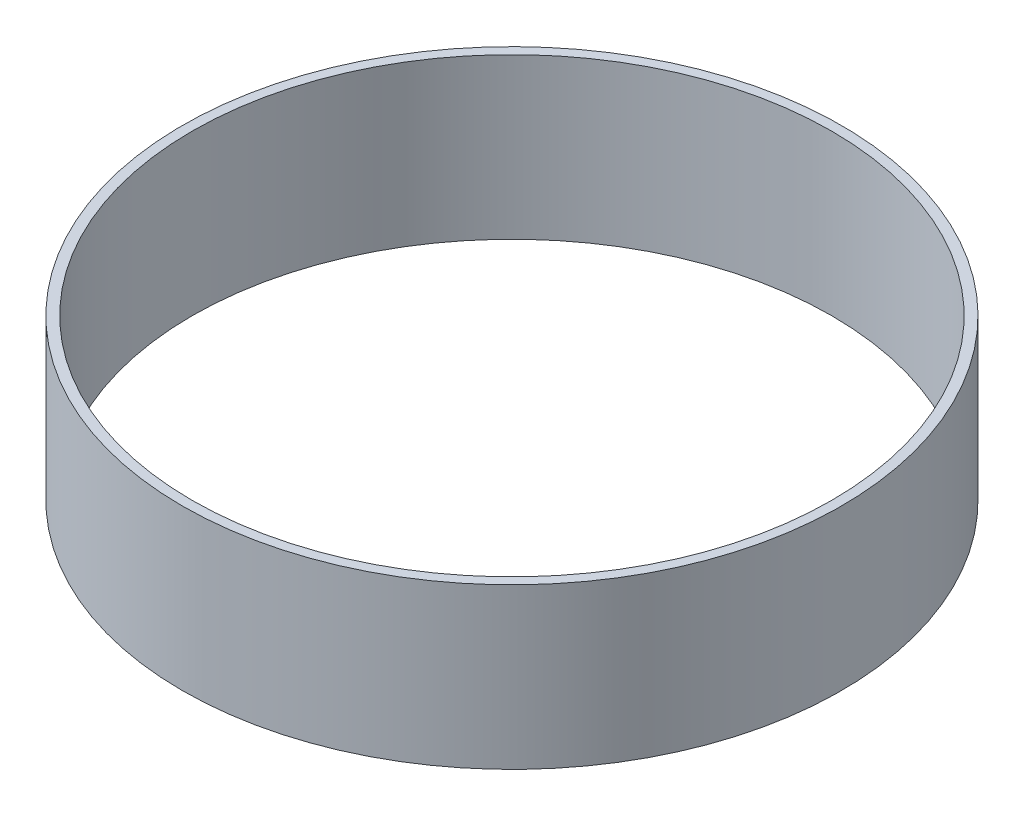
from build123d import *

# Parameters (mm, degrees)
SKETCH1_R           = 65.4431
SKETCH1_R_2         = 63.5
BOSS_EXTRUDE2_DEPTH = 31.75


with BuildPart() as part:
    # Sketch1 → Boss-Extrude2 (new body)
    with BuildSketch(Plane(origin=(0, 0, 0), x_dir=(1, 0, 0), z_dir=(0, 1, 0))):
        Circle(SKETCH1_R)
        Circle(SKETCH1_R_2, mode=Mode.SUBTRACT)
    extrude(amount=BOSS_EXTRUDE2_DEPTH)


solid = part.part
